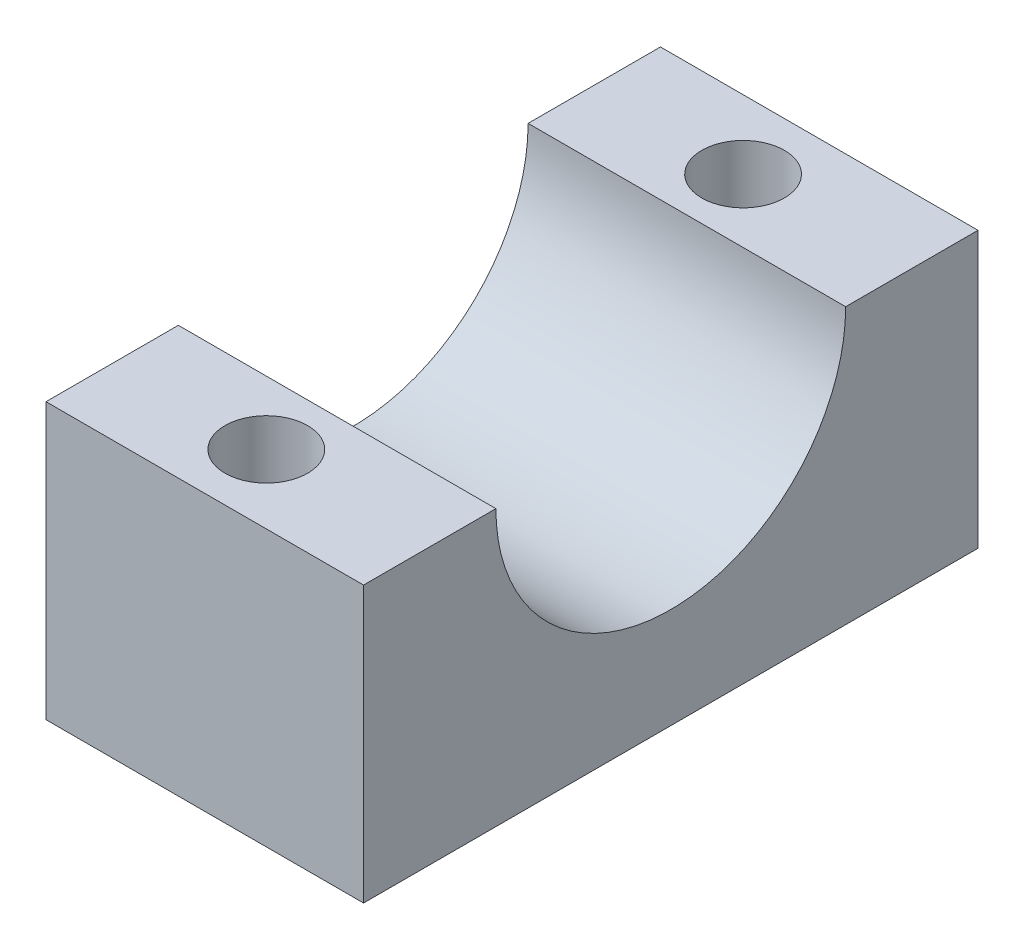
from build123d import *

# Parameters (mm, degrees)
BOSS_EXTRUDE1_DEPTH = 11.53
SKETCH2_R           = 1.5
CUT_EXTRUDE1_DEPTH  = 10


with BuildPart() as part:
    # Sketch1 → Boss-Extrude1 (new body)
    with BuildSketch(Plane(origin=(0, 0, 0), x_dir=(0, 0, -1), z_dir=(1, 0, 0))):
        with BuildLine():
            Line((-6.35, 5), (-11.155, 5))
            Line((-11.155, 5), (-11.155, -5))
            Line((-11.155, -5), (-6.155, -5))
            Line((-6.155, -5), (6.155, -5))
            Line((6.155, -5), (11.155, -5))
            Line((11.155, -5), (11.155, 5))
            Line((11.155, 5), (6.35, 5))
            ThreePointArc((6.35, 5), (0, -1.35), (-6.35, 5))
        make_face()
    extrude(amount=BOSS_EXTRUDE1_DEPTH)

    # Sketch2 → Cut-Extrude1 (cut)
    with BuildSketch(Plane(origin=(0, 5, 0), x_dir=(1, 0, 0), z_dir=(0, 1, 0))):
        with Locations((5.5, -8.655)):
            Circle(SKETCH2_R)
        with Locations((5.5, 8.655)):
            Circle(SKETCH2_R)
    extrude(amount=-CUT_EXTRUDE1_DEPTH, mode=Mode.SUBTRACT)


solid = part.part
